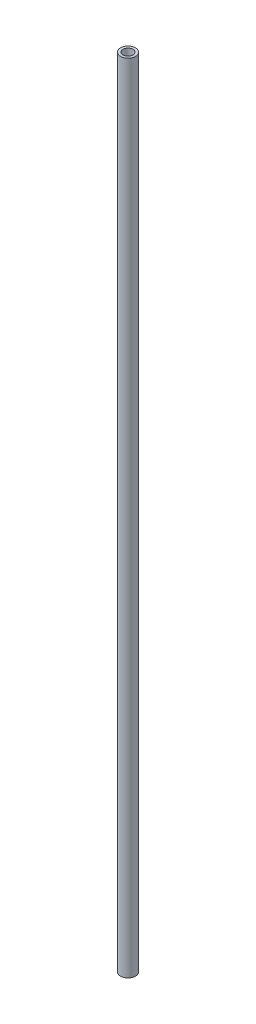
from build123d import *

# Parameters (mm, degrees)
SKETCH1_R           = 9.525
SKETCH1_R_2         = 6.35
BOSS_EXTRUDE1_DEPTH = 1016


with BuildPart() as part:
    # Sketch1 → Boss-Extrude1 (new body)
    with BuildSketch(Plane(origin=(0, 0, 0), x_dir=(1, 0, 0), z_dir=(0, 1, 0))):
        Circle(SKETCH1_R)
        Circle(SKETCH1_R_2, mode=Mode.SUBTRACT)
    extrude(amount=BOSS_EXTRUDE1_DEPTH)


solid = part.part
